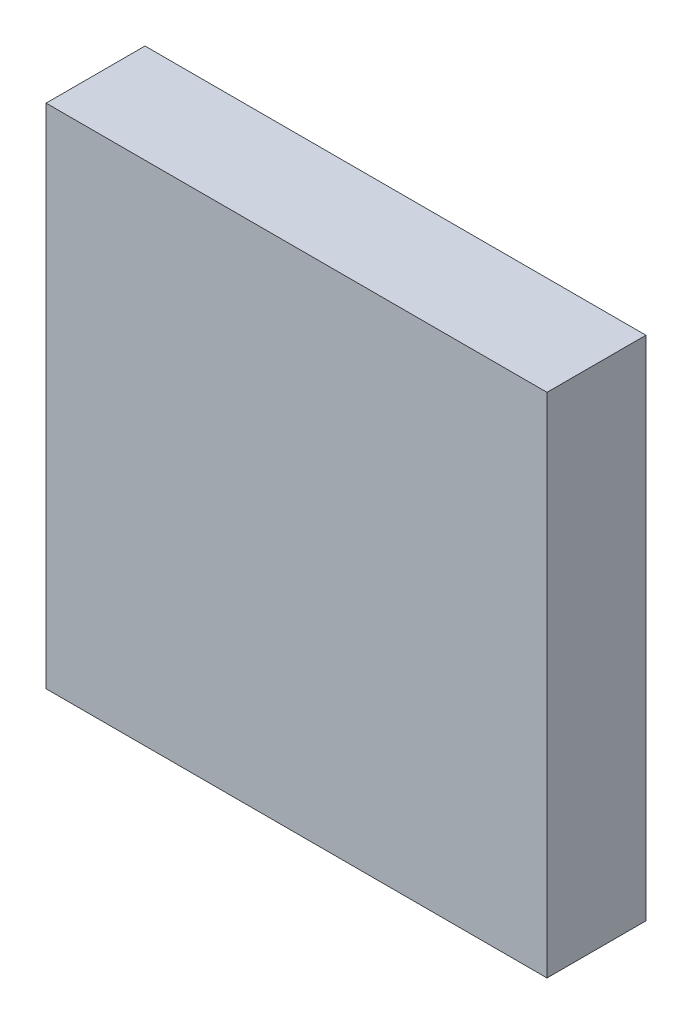
from build123d import *

# Parameters (mm, degrees)
SKETCH1_W               = 8.1026
SKETCH1_H               = 8.2042
COMPONENT_OUTLINE_DEPTH = 1.599946


with BuildPart() as part:
    # Sketch1 → Component_Outline (new body)
    with BuildSketch(Plane.XY):
        Rectangle(SKETCH1_W, SKETCH1_H)
    extrude(amount=COMPONENT_OUTLINE_DEPTH)


solid = part.part
